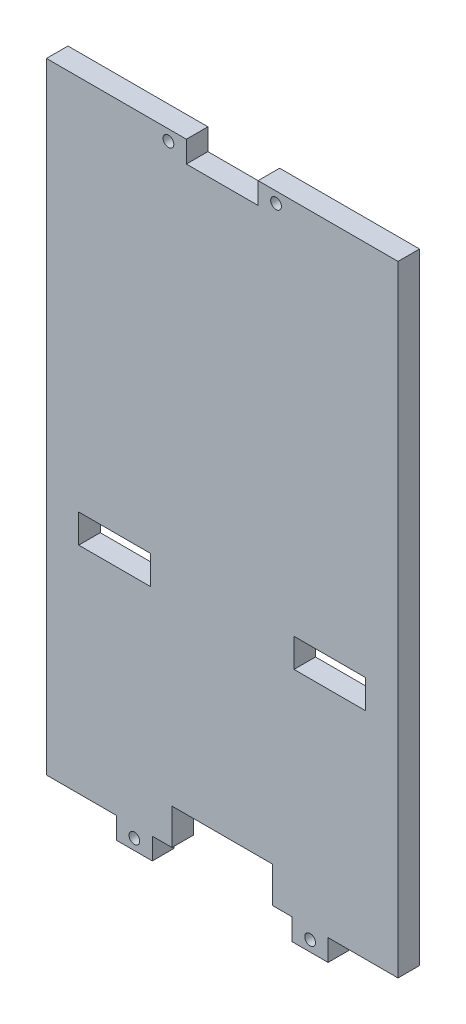
from build123d import *

# Parameters (mm, degrees)
ESQUISSE1_W             = 98
ESQUISSE1_H             = 173
ESQUISSE1_W_2           = 20
ESQUISSE1_H_2           = 8
BOSS_EXTRU_1_DEPTH      = 6
ESQUISSE2_W             = 10
ESQUISSE2_H             = 6
BOSS_EXTRU_2_DEPTH      = 6
ESQUISSE3_R             = 1.5
ENL_V_MAT_EXTRU_1_DEPTH = 6
ESQUISSE4_W             = 20
ESQUISSE4_H             = 6
ESQUISSE4_W_2           = 28
ESQUISSE4_H_2           = 10
ENL_V_MAT_EXTRU_2_DEPTH = 6


with BuildPart() as part:
    # Esquisse1 → Boss.-Extru.1 (new body)
    with BuildSketch(Plane.XY):
        Rectangle(ESQUISSE1_W, ESQUISSE1_H)
        with Locations((30, -22.5)):
            Rectangle(ESQUISSE1_W_2, ESQUISSE1_H_2, mode=Mode.SUBTRACT)
        with Locations((-30, -22.5)):
            Rectangle(ESQUISSE1_W_2, ESQUISSE1_H_2, mode=Mode.SUBTRACT)
    extrude(amount=BOSS_EXTRU_1_DEPTH)

    # Esquisse2 → Boss.-Extru.2 (add)
    with BuildSketch(Plane.XY.offset(6)):
        with Locations((24.5, -89.5)):
            Rectangle(ESQUISSE2_W, ESQUISSE2_H)
        with Locations((-24.5, -89.5)):
            Rectangle(ESQUISSE2_W, ESQUISSE2_H)
    extrude(amount=-BOSS_EXTRU_2_DEPTH)

    # Esquisse3 → Enlèv. mat.-Extru.1 (cut)
    with BuildSketch(Plane.XY.offset(6)):
        with Locations((-15, 83.5)):
            Circle(ESQUISSE3_R)
        with Locations((24.5, -89.5)):
            Circle(ESQUISSE3_R)
        with Locations((-24.5, -89.5)):
            Circle(ESQUISSE3_R)
        with Locations((15, 83.5)):
            Circle(ESQUISSE3_R)
    extrude(amount=-ENL_V_MAT_EXTRU_1_DEPTH, mode=Mode.SUBTRACT)

    # Esquisse4 → Enlèv. mat.-Extru.2 (cut)
    with BuildSketch(Plane.XY.offset(6)):
        with Locations((0, 83.5)):
            Rectangle(ESQUISSE4_W, ESQUISSE4_H)
        with Locations((0, -81.5)):
            Rectangle(ESQUISSE4_W_2, ESQUISSE4_H_2)
    extrude(amount=-ENL_V_MAT_EXTRU_2_DEPTH, mode=Mode.SUBTRACT)


solid = part.part
